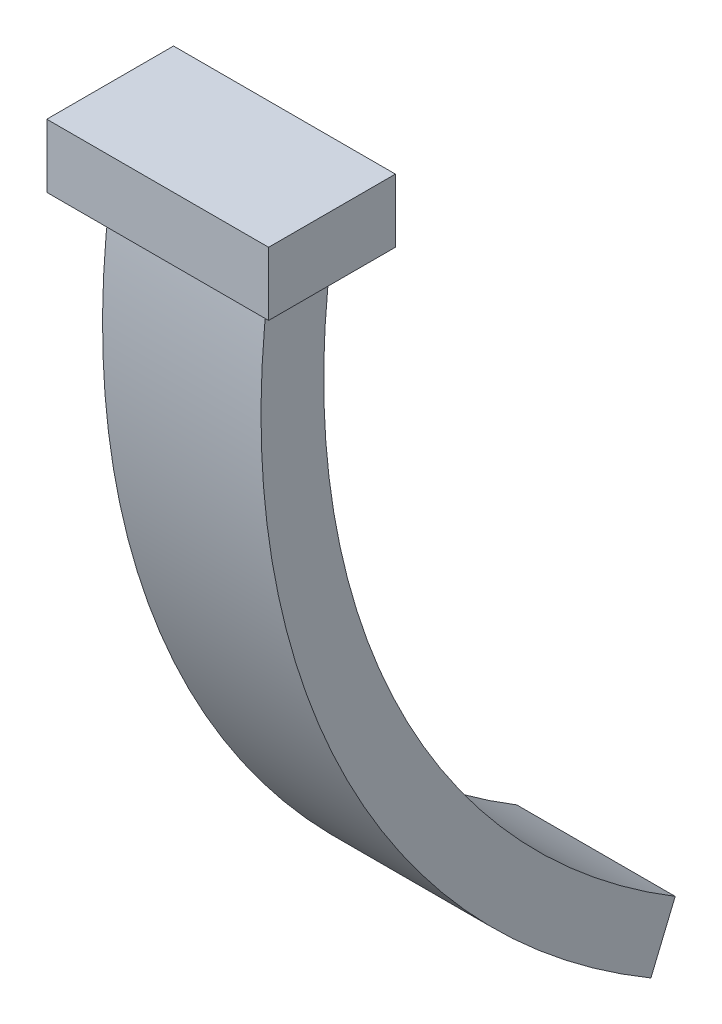
from build123d import *

# Parameters (mm, degrees)
IZIM1_W                     = 5
IZIM1_H                     = 2
IZIM3_W                     = 5
IZIM3_H                     = 2
IZIM3_W_2                   = 7
IZIM3_H_2                   = 4
Y_KSEKLIK_EKSTR_ZYON1_DEPTH = 2


with BuildPart() as part:
    # Süpür1: sweep along a path in Çizim2
    with BuildLine(Plane(origin=(0, 0, 0), x_dir=(0, 0, -1), z_dir=(1, 0, 0))) as s_p_r1_path:
        ThreePointArc((0, 0), (2.242898882, -14.32797835), (12.06275188, -25))
    # Çizim1 → Süpür1 (sweep)
    with BuildSketch(Plane(origin=(0, 0, 0), x_dir=(1, 0, 0), z_dir=(0, 1, 0))):
        with Locations((2.5, 1)):
            Rectangle(IZIM1_W, IZIM1_H)
    sweep(path=s_p_r1_path.line)

    # Çizim3 → Yükseklik-Ekstrüzyon1 (add)
    with BuildSketch(Plane(origin=(0, 0, 0), x_dir=(1, 0, 0), z_dir=(0, 1, 0))):
        with Locations((2.5, 1)):
            Rectangle(IZIM3_W, IZIM3_H)
        with Locations((2.5, 1)):
            Rectangle(IZIM3_W_2, IZIM3_H_2)
        with Locations((2.5, 1)):
            Rectangle(IZIM3_W, IZIM3_H, mode=Mode.SUBTRACT)
        with Locations((2.5, 1)):
            Rectangle(IZIM3_W, IZIM3_H)
    extrude(amount=Y_KSEKLIK_EKSTR_ZYON1_DEPTH)


solid = part.part
